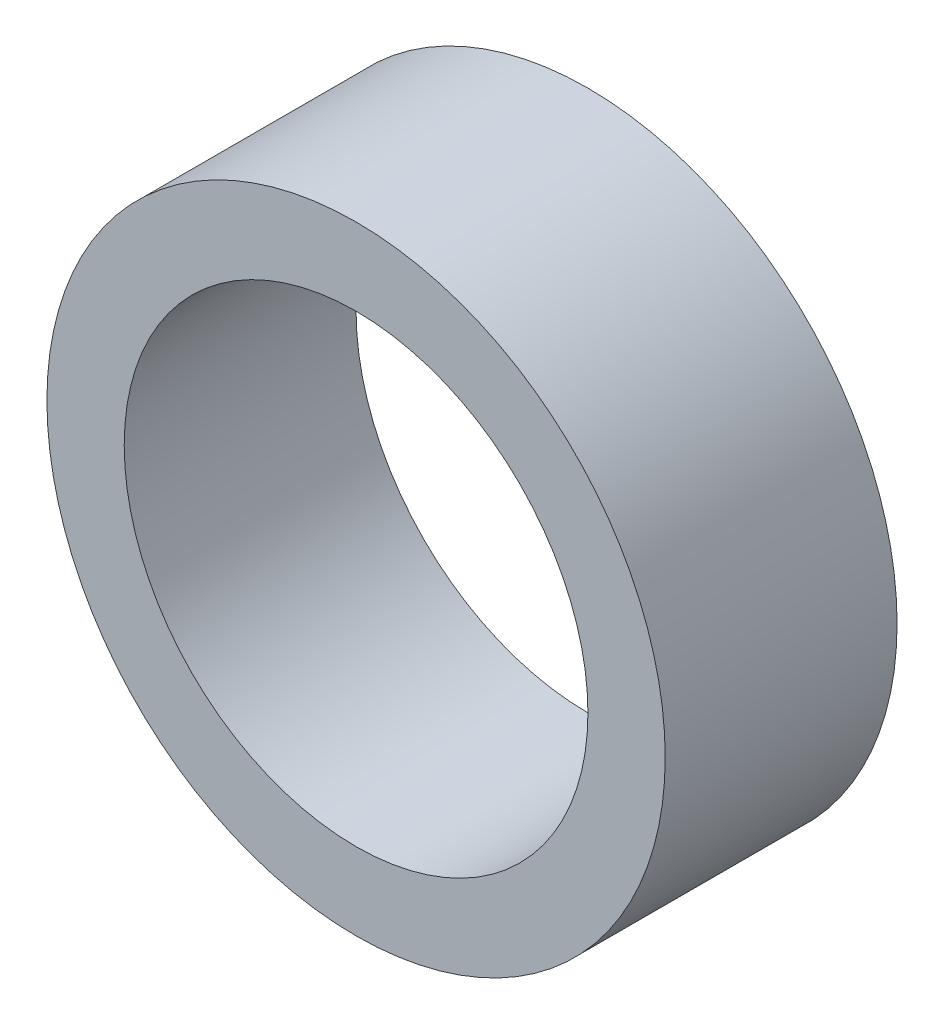
from build123d import *

# Parameters (mm, degrees)
SKETCH1_R           = 12.7
SKETCH1_R_2         = 9.525
BOSS_EXTRUDE1_DEPTH = 9.525


with BuildPart() as part:
    # Sketch1 → Boss-Extrude1 (new body)
    with BuildSketch(Plane.XY):
        Circle(SKETCH1_R)
        Circle(SKETCH1_R_2, mode=Mode.SUBTRACT)
    extrude(amount=BOSS_EXTRUDE1_DEPTH)


solid = part.part
